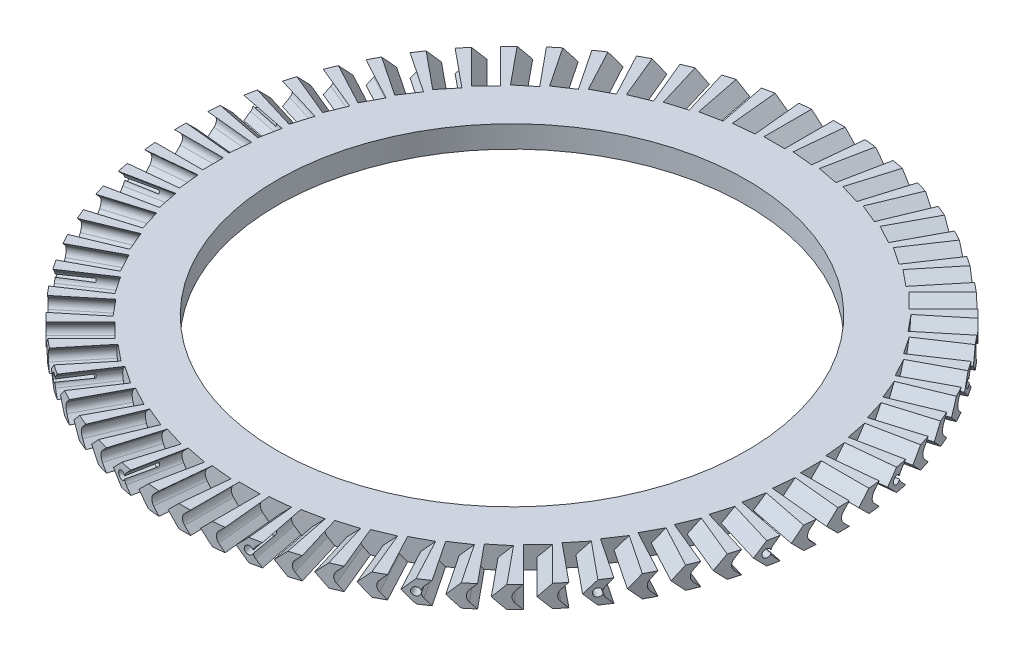
from build123d import *

# Parameters (mm, degrees)
DISC_DEPTH        = 4.7625
DISC_DEPTH_BACK   = 4.7625
SKETCH1_R         = 142.6972
SKETCH1_R_2       = 101.6
BLADES_DEPTH      = 21.158199999999997
CIRPATTERN1_COUNT = 64
CIRPATTERN2_COUNT = 16


with BuildPart() as part:
    # Sketch1 → Disc (new, two sides: drawn at the far end of the back side and taken through both)
    with BuildSketch(Plane(origin=(0, 0, 0), x_dir=(1, 0, 0), z_dir=(0, 1, 0)).offset(-DISC_DEPTH_BACK)):
        Circle(SKETCH1_R)
        Circle(SKETCH1_R_2, mode=Mode.SUBTRACT)
    extrude(amount=DISC_DEPTH + DISC_DEPTH_BACK)

    # Sketch2 → Blades (cut)
    with BuildSketch(Plane(origin=(-100.90215777633244, 0, -100.90215777633352), x_dir=(0, -1, 0), z_dir=(-0.7071067811865438, 0, -0.7071067811865512))):
        with BuildLine():
            Line((4.762500000000001, 12.427628060534655), (0, 7.6651280605346))
            Line((4.4e-16, 7.6651280605346), (-4.7625, 12.427628060534657))
            Line((-4.7625, 12.427628060534657), (-4.7625, 3.447371939465448))
            Line((-4.7625, 3.447371939465448), (-2.2450640302672995, 0.9299359697327232))
            ThreePointArc((-2.2450640302673004, 0.9299359697327239), (-5.8e-16, 0), (2.2450640302672995, 0.929935969732723))
            Line((2.245064030267301, 0.9299359697327241), (4.7625, 3.44737193946545))
            Line((4.7625, 3.44737193946545), (4.762500000000001, 12.427628060534655))
        make_face()
    blades = extrude(amount=-BLADES_DEPTH, mode=Mode.SUBTRACT)

    # CirPattern1: Blades ×64 about axis
    cirpattern1_axis = Axis((0, -4.7625, 0), (0, 1, 0))
    for i in range(1, CIRPATTERN1_COUNT):
        add(blades.rotate(cirpattern1_axis, i * 360 / CIRPATTERN1_COUNT), mode=Mode.SUBTRACT)

    # Sketch4 → Tap Drill for _8-32 Tap1 (revolve, cut)
    with BuildSketch(Plane(origin=(-140.25236748953913, -8.7e-16, 26.301412536578436), x_dir=(0.18431624822756462, 0, 0.9828669903091237), z_dir=(1e-17, 1, 0))):
        Polygon((0, 0), (-3.39e-15, 13.737806461184404), (1.727199999999997, 12.7), (1.7271999999999983, -4e-17), align=None)
    tap_drill_for_8_32_tap1 = revolve(axis=Axis((-146.49357287800206, -7.9e-16, 27.47182071282347), (0.9828669903091235, 0, -0.18431624822756457)), mode=Mode.SUBTRACT)

    # CirPattern2: Tap Drill for _8-32 Tap1 ×16 about axis
    cirpattern2_axis = Axis((0, -4.7625, 0), (0, 1, 0))
    for i in range(1, CIRPATTERN2_COUNT):
        add(tap_drill_for_8_32_tap1.rotate(cirpattern2_axis, i * 360 / CIRPATTERN2_COUNT), mode=Mode.SUBTRACT)


solid = part.part
